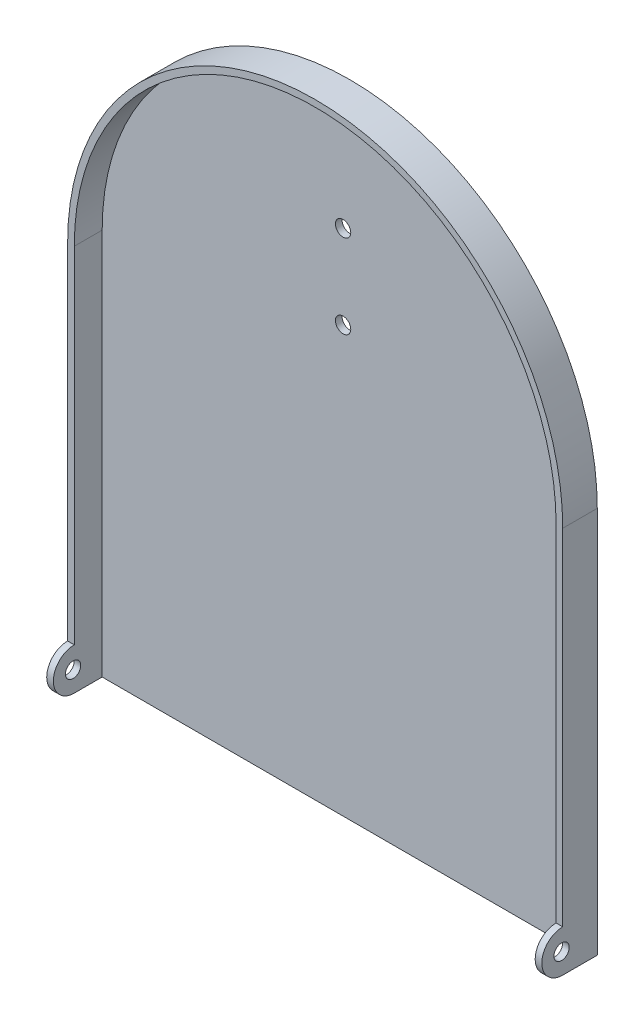
from build123d import *

# Parameters (mm, degrees)
BOSS_EXTRUDE1_DEPTH = 2.38
BOSS_EXTRUDE2_DEPTH = 10
BOSS_EXTRUDE3_DEPTH = 2.38
BOSS_EXTRUDE4_DEPTH = 2.38
SKETCH5_R           = 2.75
CUT_EXTRUDE1_DEPTH  = 178.5
SKETCH6_R           = 2.75
CUT_EXTRUDE2_DEPTH  = 20.88


with BuildPart() as part:
    # Sketch1 → Boss-Extrude1 (new body)
    with BuildSketch(Plane.XY):
        with BuildLine():
            Line((0, 0), (177.5, 0))
            Line((177.5, 0), (177.5, 138.75))
            ThreePointArc((177.5, 138.75), (88.75, 227.5), (0, 138.75))
            Line((0, 138.75), (0, 0))
        make_face()
    extrude(amount=BOSS_EXTRUDE1_DEPTH)

    # Sketch2 → Boss-Extrude2 (add)
    with BuildSketch(Plane.XY.offset(2.38)):
        with BuildLine():
            Line((175.12, 2.38), (175.12, 138.75))
            ThreePointArc((175.12, 138.75), (88.75, 225.12), (2.38, 138.75))
            Line((2.38, 138.75), (2.38, 2.38))
            Line((2.38, 2.38), (2.38, 0))
            Line((2.38, 0), (0, 0))
            Line((0, 0), (0, 138.75))
            ThreePointArc((0, 138.75), (88.75, 227.5), (177.5, 138.75))
            Line((177.5, 138.75), (177.5, 0))
            Line((177.5, 0), (175.12, 0))
            Line((175.12, 0), (175.12, 2.38))
        make_face()
    extrude(amount=BOSS_EXTRUDE2_DEPTH)

    # Sketch3 → Boss-Extrude3 (add)
    with BuildSketch(Plane(origin=(177.5, 0, 0), x_dir=(0, 0, -1), z_dir=(1, 0, 0))):
        with BuildLine():
            Line((-12.38, 15), (-12.38, 0))
            ThreePointArc((-12.38, 0), (-19.88, 7.5), (-12.38, 15))
        make_face()
    extrude(amount=-BOSS_EXTRUDE3_DEPTH)

    # Sketch4 → Boss-Extrude4 (add)
    with BuildSketch(Plane.ZY):
        with BuildLine():
            Line((12.38, 15), (12.38, 0))
            ThreePointArc((12.38, 0), (19.88, 7.5), (12.38, 15))
        make_face()
    extrude(amount=-BOSS_EXTRUDE4_DEPTH)

    # Sketch5 → Cut-Extrude1 (cut, through all)
    with BuildSketch(Plane.ZY):
        with Locations((12.807918023, 7.485123177)):
            Circle(SKETCH5_R)
    extrude(amount=-CUT_EXTRUDE1_DEPTH, mode=Mode.SUBTRACT)

    # Sketch6 → Cut-Extrude2 (cut, through all)
    with BuildSketch(Plane(origin=(0, 0, 0), x_dir=(-1, 0, 0), z_dir=(0, 0, -1))):
        with Locations((-88.75, 182.5)):
            Circle(SKETCH6_R)
        with Locations((-88.75, 152.5)):
            Circle(SKETCH6_R)
    extrude(amount=-CUT_EXTRUDE2_DEPTH, mode=Mode.SUBTRACT)


solid = part.part
